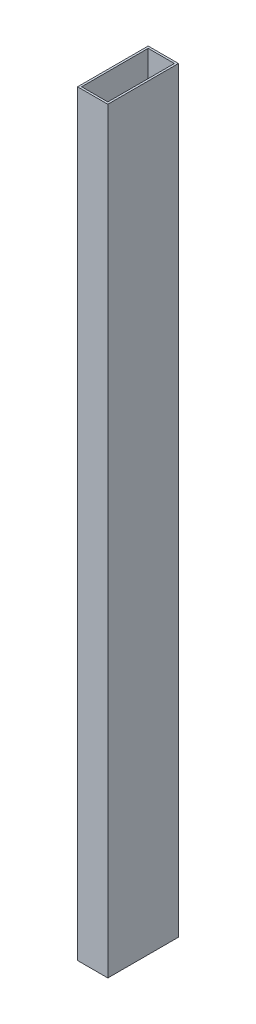
from build123d import *

# Parameters (mm, degrees)
SKETCH_1_W          = 30
SKETCH_1_H          = 750
EXTRUDE_2_DEPTH     = 70
SKETCH_2_W          = 26
SKETCH_2_H          = 66
CUT_EXTRUDE_3_DEPTH = 751


with BuildPart() as part:
    # 草图1 → 凸台-拉伸2 (new body)
    with BuildSketch(Plane.XY):
        Rectangle(SKETCH_1_W, SKETCH_1_H)
    extrude(amount=EXTRUDE_2_DEPTH)

    # 草图2 → 切除-拉伸3 (cut, through all)
    with BuildSketch(Plane.XZ.offset(375)):
        with Locations((0, 35)):
            Rectangle(SKETCH_2_W, SKETCH_2_H)
    extrude(amount=-CUT_EXTRUDE_3_DEPTH, mode=Mode.SUBTRACT)


solid = part.part
